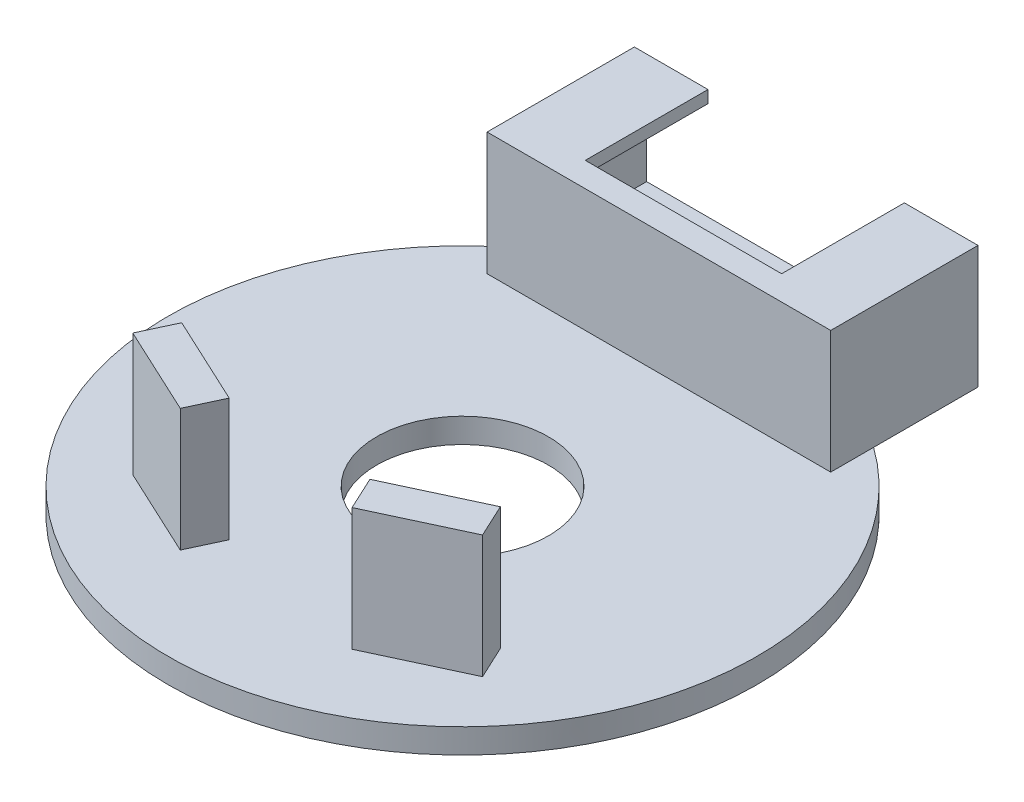
from build123d import *

# Parameters (mm, degrees)
SKETCH1_R           = 12
SKETCH1_R_2         = 3.5
BOSS_EXTRUDE1_DEPTH = 0.5
SKETCH2_W           = 14
SKETCH2_H           = 6
BOSS_EXTRUDE2_DEPTH = 5
SKETCH3_W           = 13
SKETCH3_H           = 4
CUT_EXTRUDE1_DEPTH  = 5
SKETCH4_W           = 8
SKETCH4_H           = 5
CUT_EXTRUDE2_DEPTH  = 4.5
BOSS_EXTRUDE3_DEPTH = 5


with BuildPart() as part:
    # Sketch1 → Boss-Extrude1 (new body, symmetric)
    with BuildSketch(Plane(origin=(0, 0, 0), x_dir=(1, 0, 0), z_dir=(0, 1, 0))):
        Circle(SKETCH1_R)
        Circle(SKETCH1_R_2, mode=Mode.SUBTRACT)
    extrude(amount=BOSS_EXTRUDE1_DEPTH, both=True)

    # Sketch2 → Boss-Extrude2 (add)
    with BuildSketch(Plane(origin=(0, 0.5, 0), x_dir=(1, 0, 0), z_dir=(0, 1, 0))):
        with Locations((0, 11)):
            Rectangle(SKETCH2_W, SKETCH2_H)
    extrude(amount=BOSS_EXTRUDE2_DEPTH)

    # Sketch3 → Cut-Extrude1 (cut)
    with BuildSketch(Plane(origin=(0, 0, -14), x_dir=(-1, 0, 0), z_dir=(0, 0, -1))):
        with Locations((0, 3)):
            Rectangle(SKETCH3_W, SKETCH3_H)
    extrude(amount=-CUT_EXTRUDE1_DEPTH, mode=Mode.SUBTRACT)

    # Sketch4 → Cut-Extrude2 (cut)
    with BuildSketch(Plane(origin=(0, 5.5, 0), x_dir=(1, 0, 0), z_dir=(0, 1, 0))):
        with Locations((0, 11.5)):
            Rectangle(SKETCH4_W, SKETCH4_H)
    extrude(amount=-CUT_EXTRUDE2_DEPTH, mode=Mode.SUBTRACT)

    # Sketch5 → Boss-Extrude3 (add)
    with BuildSketch(Plane(origin=(0, 0.5, 0), x_dir=(1, 0, 0), z_dir=(0, 1, 0))):
        Polygon((-6.491303756, -4.950065272), (-2.866072607, -6.640538319), (-3.5, -8), (-7.125231148, -6.309526953), align=None)
        Polygon((7.125231148, -6.309526953), (6.491303756, -4.950065272), (2.866072607, -6.640538319), (3.5, -8), align=None)
    extrude(amount=BOSS_EXTRUDE3_DEPTH)


solid = part.part
